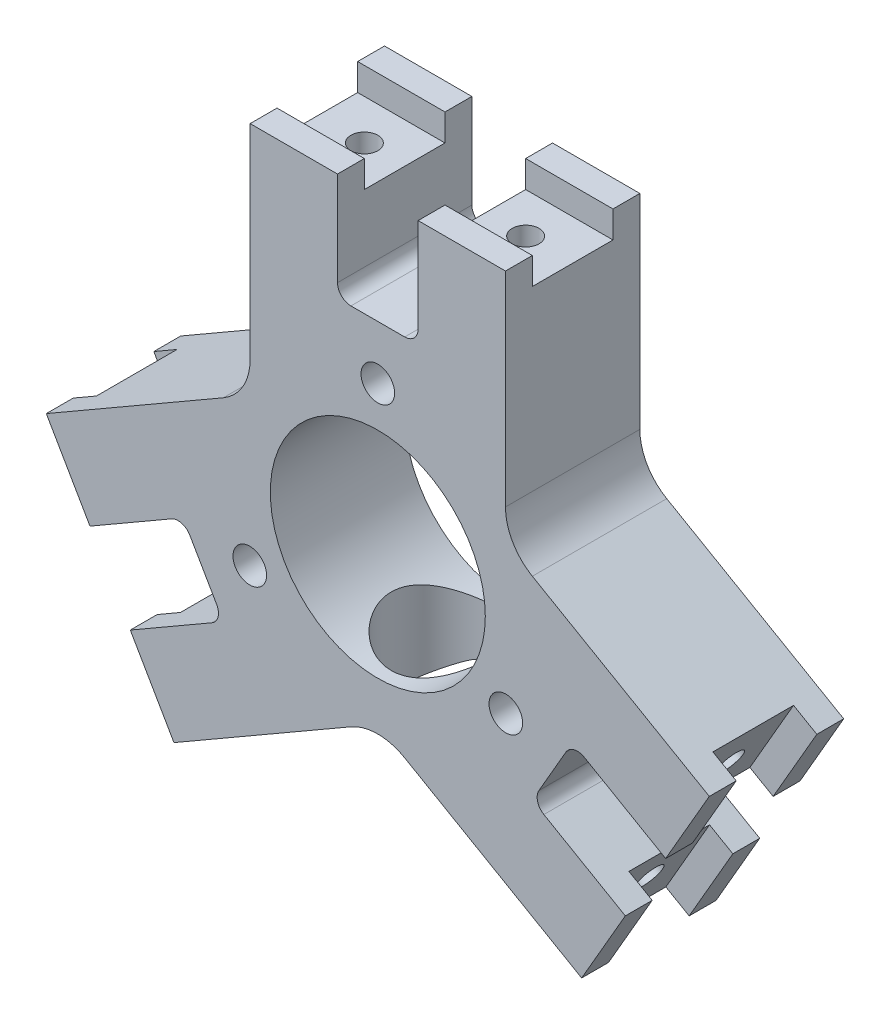
from build123d import *

# Parameters (mm, degrees)
BOSS_EXTRU_1_DEPTH           = 5
BOSS_EXTRU_1_DEPTH_BACK      = 5
ESQUISSE1_R                  = 1.25
ESQUISSE1_R_2                = 8
ESQUISSE2_W                  = 6
ESQUISSE2_H                  = 2
ENL_V_MAT_EXTRU_1_DEPTH      = 19
ESQUISSE3_R                  = 1
ENL_V_MAT_EXTRU_2_DEPTH      = 5
R_P_TITION_CIRCULAIRE1_COUNT = 3
ESQUISSE5_R                  = 4
ENL_V_MAT_EXTRU_5_DEPTH      = 18


with BuildPart() as part:
    # Esquisse1 → Boss.-Extru.1 (new, two sides: drawn at the far end of the back side and taken through both)
    with BuildSketch(Plane.XY.offset(-BOSS_EXTRU_1_DEPTH_BACK)):
        with BuildLine():
            Line((21.418584287, -8.901923789), (24.668584287, -3.272758664))
            Line((24.668584287, -3.272758664), (11.5, 4.330127019))
            ThreePointArc((11.5, 4.330127019), (10.035898385, 5.794228634), (9.5, 7.794228634))
            Line((9.5, 7.794228634), (9.5, 23))
            Line((9.5, 23), (3, 23))
            Line((3, 23), (3, 16))
            ThreePointArc((3, 16), (2.707106781, 15.292893219), (2, 15))
            Line((2, 15), (-2, 15))
            ThreePointArc((-2, 15), (-2.707106781, 15.292893219), (-3, 16))
            Line((-3, 16), (-3, 23))
            Line((-3, 23), (-9.5, 23))
            Line((-9.5, 23), (-9.5, 7.794228634))
            ThreePointArc((-9.5, 7.794228634), (-10.035898385, 5.794228634), (-11.5, 4.330127019))
            Line((-11.5, 4.330127019), (-24.668584287, -3.272758664))
            Line((-24.668584287, -3.272758664), (-21.418584287, -8.901923789))
            Line((-21.418584287, -8.901923789), (-15.356406461, -5.401923789))
            ThreePointArc((-15.356406461, -5.401923789), (-14.597587415, -5.302023366), (-13.990381057, -5.767949192))
            Line((-13.990381057, -5.767949192), (-11.990381057, -9.232050808))
            ThreePointArc((-11.990381057, -9.232050808), (-11.890480634, -9.990869853), (-12.356406461, -10.598076211))
            Line((-12.356406461, -10.598076211), (-18.418584287, -14.098076211))
            Line((-18.418584287, -14.098076211), (-15.168584287, -19.727241336))
            Line((-15.168584287, -19.727241336), (-2, -12.124355653))
            ThreePointArc((-2, -12.124355653), (0, -11.588457268), (2, -12.124355653))
            Line((2, -12.124355653), (15.168584287, -19.727241336))
            Line((15.168584287, -19.727241336), (18.418584287, -14.098076211))
            Line((18.418584287, -14.098076211), (12.356406461, -10.598076211))
            ThreePointArc((12.356406461, -10.598076211), (11.890480634, -9.990869853), (11.990381057, -9.232050808))
            Line((11.990381057, -9.232050808), (13.990381057, -5.767949192))
            ThreePointArc((13.990381057, -5.767949192), (14.597587415, -5.302023366), (15.356406461, -5.401923789))
            Line((15.356406461, -5.401923789), (21.418584287, -8.901923789))
        make_face()
        with Locations((-9.526279442, -5.5)):
            Circle(ESQUISSE1_R, mode=Mode.SUBTRACT)
        Circle(ESQUISSE1_R_2, mode=Mode.SUBTRACT)
        with Locations((9.526279442, -5.5)):
            Circle(ESQUISSE1_R, mode=Mode.SUBTRACT)
        with Locations((0, 11)):
            Circle(ESQUISSE1_R, mode=Mode.SUBTRACT)
    extrude(amount=BOSS_EXTRU_1_DEPTH + BOSS_EXTRU_1_DEPTH_BACK)

    # Esquisse2 → Enlèv. mat.-Extru.1 (cut)
    with BuildSketch(Plane.ZY.offset(9.5)):
        with Locations((0, 22)):
            Rectangle(ESQUISSE2_W, ESQUISSE2_H)
    enl_v_mat_extru_1 = extrude(amount=-ENL_V_MAT_EXTRU_1_DEPTH, mode=Mode.SUBTRACT)

    # Esquisse3 → Enlèv. mat.-Extru.2 (cut)
    with BuildSketch(Plane(origin=(0, 21, 0), x_dir=(1, 0, 0), z_dir=(0, 1, 0))):
        with Locations((-6, 0)):
            Circle(ESQUISSE3_R)
        with Locations((6, 0)):
            Circle(ESQUISSE3_R)
    enl_v_mat_extru_2 = extrude(amount=-ENL_V_MAT_EXTRU_2_DEPTH, mode=Mode.SUBTRACT)

    # Répétition circulaire1: Enlèv. mat.-Extru.1, Enlèv. mat.-Extru.2 ×3 about axis
    r_p_tition_circulaire1_axis = Axis((0, 0, -5), (0, 0, 1))
    add([enl_v_mat_extru_1.rotate(r_p_tition_circulaire1_axis, i * 360 / R_P_TITION_CIRCULAIRE1_COUNT) for i in range(1, R_P_TITION_CIRCULAIRE1_COUNT)], mode=Mode.SUBTRACT)
    add([enl_v_mat_extru_2.rotate(r_p_tition_circulaire1_axis, i * 360 / R_P_TITION_CIRCULAIRE1_COUNT) for i in range(1, R_P_TITION_CIRCULAIRE1_COUNT)], mode=Mode.SUBTRACT)

    # Esquisse5 → Enlèv. mat.-Extru.5 (cut)
    with BuildSketch(Plane(origin=(0, 0, 0), x_dir=(1, 0, 0), z_dir=(0, 1, 0))):
        Circle(ESQUISSE5_R)
    extrude(amount=-ENL_V_MAT_EXTRU_5_DEPTH, mode=Mode.SUBTRACT)


solid = part.part
